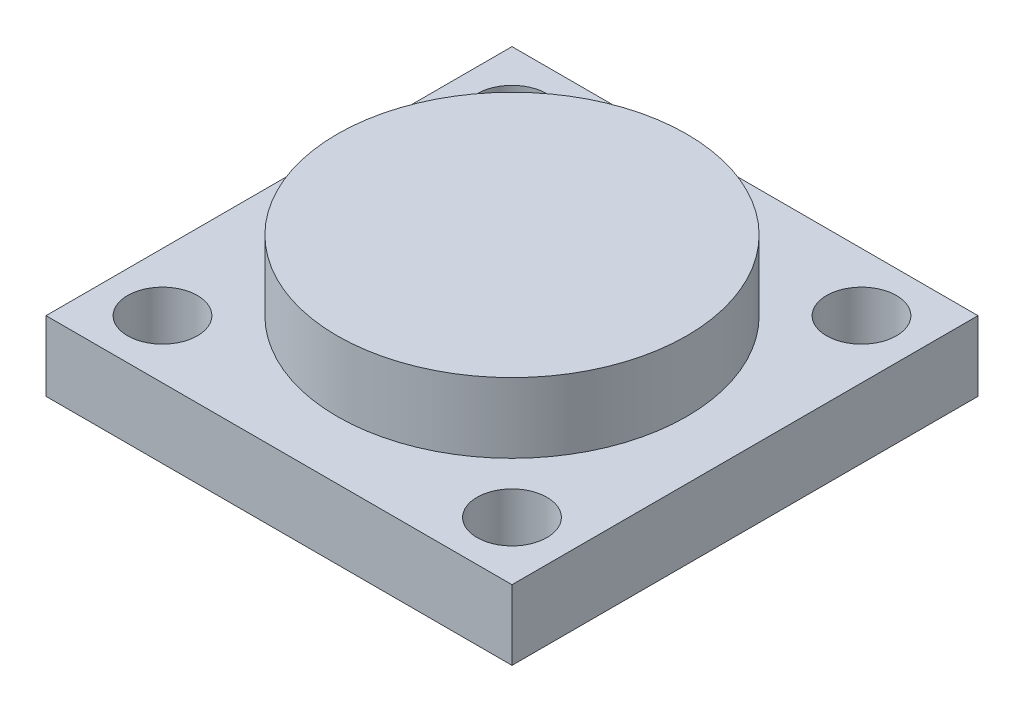
from build123d import *

# Parameters (mm, degrees)
SKETCH1_W           = 200
SKETCH1_H           = 200
BOSS_EXTRUDE1_DEPTH = 30
SKETCH3_R           = 75
BOSS_EXTRUDE2_DEPTH = 30
SKETCH4_R           = 15
CUT_EXTRUDE1_DEPTH  = 30


with BuildPart() as part:
    # Sketch1 → Boss-Extrude1 (new body)
    with BuildSketch(Plane(origin=(0, 0, 0), x_dir=(1, 0, 0), z_dir=(0, 1, 0))):
        Rectangle(SKETCH1_W, SKETCH1_H)
    extrude(amount=BOSS_EXTRUDE1_DEPTH)

    # Sketch3 → Boss-Extrude2 (add)
    with BuildSketch(Plane(origin=(0, 30, 0), x_dir=(1, 0, 0), z_dir=(0, 1, 0))):
        Circle(SKETCH3_R)
    extrude(amount=BOSS_EXTRUDE2_DEPTH)

    # Sketch4 → Cut-Extrude1 (cut)
    with BuildSketch(Plane(origin=(0, 30, 0), x_dir=(1, 0, 0), z_dir=(0, 1, 0))):
        with Locations((-75, 75)):
            Circle(SKETCH4_R)
        with Locations((-75, -75)):
            Circle(SKETCH4_R)
        with Locations((75, 75)):
            Circle(SKETCH4_R)
        with Locations((75, -75)):
            Circle(SKETCH4_R)
    extrude(amount=-CUT_EXTRUDE1_DEPTH, mode=Mode.SUBTRACT)


solid = part.part
